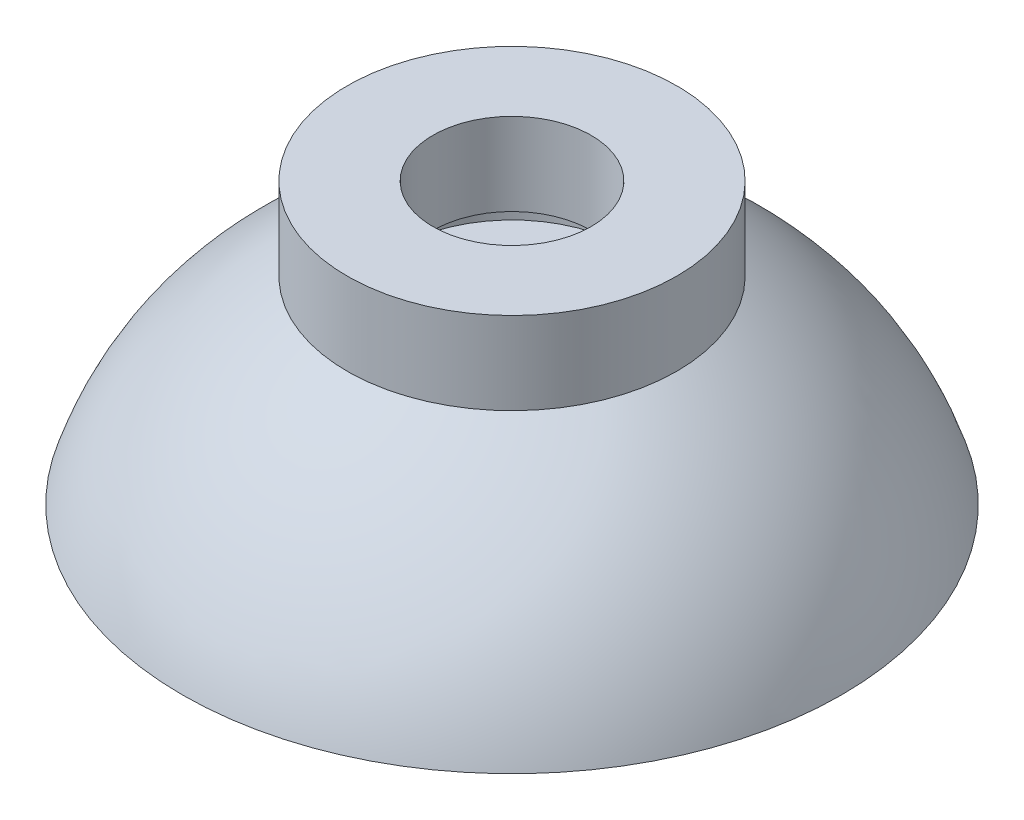
from build123d import *


with BuildPart() as part:
    # Sketch2 → Revolve3 (revolve)
    with BuildSketch(Plane.XY):
        with BuildLine():
            Line((0, -8.5), (20, -8.5))
            add(Edge.make_bspline(
                [(10, 3.5), (17.670847147, -1.003355788), (20, -8.5)],
                knots=[0, 0, 0, 1, 1, 1], degree=2))
            Line((10, 3.5), (10, 8.5))
            Line((10, 8.5), (4.8, 8.5))
            Line((4.8, 8.5), (4.8, 3.5))
            Line((4.8, 3.5), (7, 3.5))
            Line((7, 3.5), (7, 1.5))
            Line((7, 1.5), (0, 1.5))
            Line((0, 1.5), (0, -8.5))
        make_face()
    revolve(axis=Axis((0, -1018.947859526, 0), (0, 1, 0)))


solid = part.part
